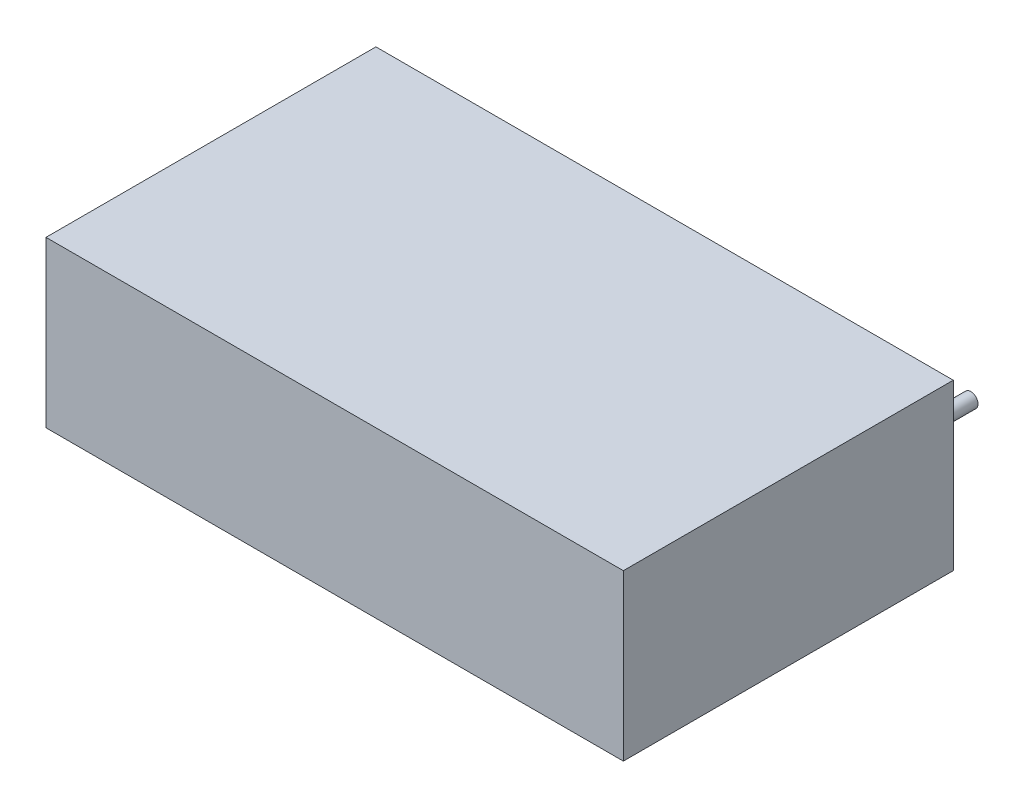
from build123d import *

# Parameters (mm, degrees)
ESQUISSE1_W        = 28
ESQUISSE1_H        = 8
BOSS_EXTRU_1_DEPTH = 16
ESQUISSE2_R        = 0.35
BOSS_EXTRU_2_DEPTH = 3.6


with BuildPart() as part:
    # Esquisse1 → Boss.-Extru.1 (new body)
    with BuildSketch(Plane.XY):
        Rectangle(ESQUISSE1_W, ESQUISSE1_H)
    extrude(amount=BOSS_EXTRU_1_DEPTH)

    # Esquisse2 → Boss.-Extru.2 (add)
    with BuildSketch(Plane(origin=(0, 0, 0), x_dir=(-1, 0, 0), z_dir=(0, 0, -1))):
        with Locations((-11.25, 0)):
            Circle(ESQUISSE2_R)
        with Locations((11.25, 0)):
            Circle(ESQUISSE2_R)
    extrude(amount=BOSS_EXTRU_2_DEPTH)


solid = part.part
